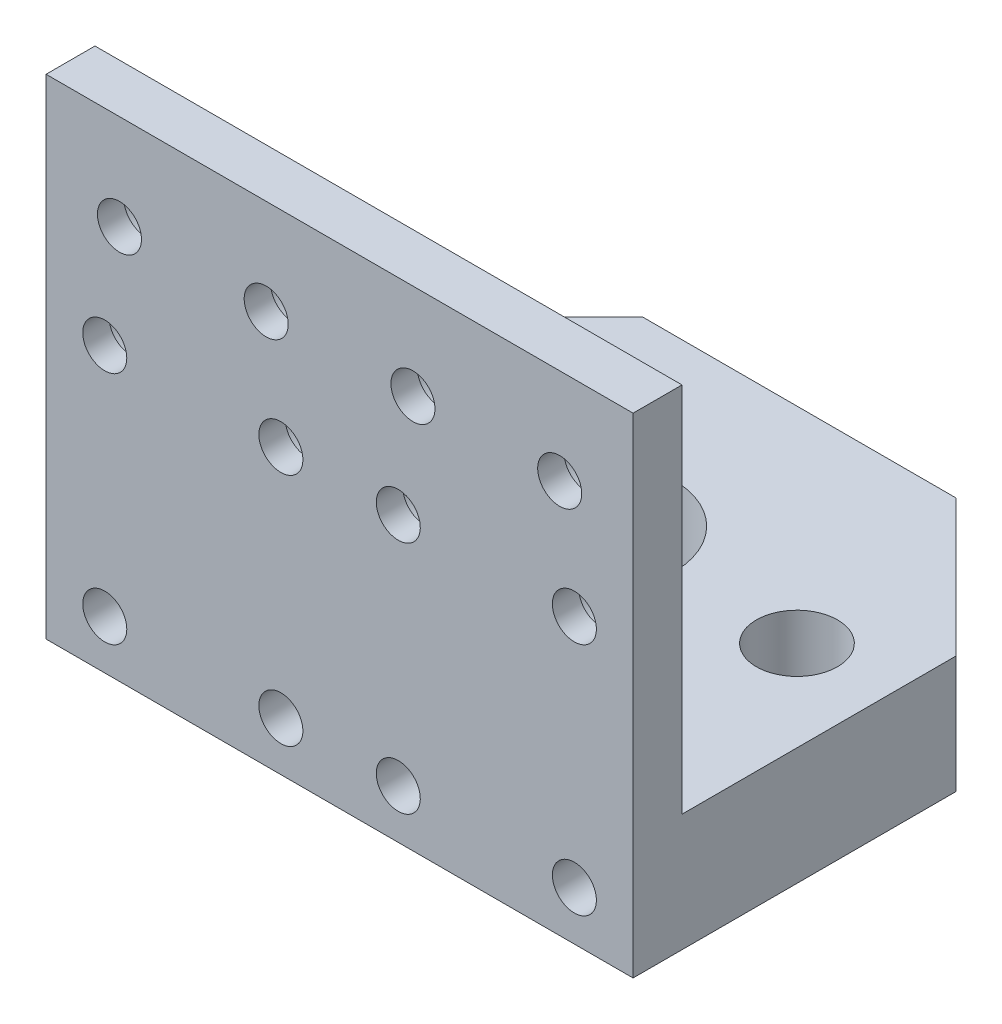
from build123d import *

# Parameters (mm, degrees)
SKETCH2_W                = 5
SKETCH2_H                = 50
BOSS_EXTRUDE1_DEPTH      = 30
BOSS_EXTRUDE1_DEPTH_BACK = 30
SKETCH3_W                = 60
SKETCH3_H                = 12
BOSS_EXTRUDE2_DEPTH      = 42
CUT_EXTRUDE1_REACH       = 49
SKETCH4_R                = 2.25
SKETCH6_R                = 4
CUT_EXTRUDE2_DEPTH       = 2.3
SKETCH7_R                = 2.25
CUT_EXTRUDE3_DEPTH       = 5
SKETCH8_R                = 4
CUT_EXTRUDE4_DEPTH       = 2.3
SKETCH9_R                = 8.15
SKETCH9_R_2              = 4.15
CUT_EXTRUDE5_DEPTH       = 10
CUT_EXTRUDE6_REACH       = 4
SKETCH10_R               = 7.5
SKETCH10_R_2             = 3
CHAMFER1_SIZE            = 14


with BuildPart() as part:
    # Sketch2 → Boss-Extrude1 (new body, two sides)
    with BuildSketch(Plane(origin=(0, 0, 0), x_dir=(0, 0, -1), z_dir=(1, 0, 0))) as boss_extrude1_sk:
        with Locations((13, -32)):
            Rectangle(SKETCH2_W, SKETCH2_H)
    extrude(amount=BOSS_EXTRUDE1_DEPTH)
    extrude(boss_extrude1_sk.sketch, amount=-BOSS_EXTRUDE1_DEPTH_BACK)

    # Sketch3 → Boss-Extrude2 (add)
    with BuildSketch(Plane(origin=(0, 0, -15.5), x_dir=(-1, 0, 0), z_dir=(0, 0, -1))):
        with Locations((0, -51)):
            Rectangle(SKETCH3_W, SKETCH3_H)
    extrude(amount=BOSS_EXTRUDE2_DEPTH)

    # Sketch4 → Cut-Extrude1 (cut, up to next)
    with BuildSketch(Plane.XY.offset(-10.5), mode=Mode.PRIVATE) as cut_extrude1_sk1:
        with Locations((-22.5, -16.75)):
            Circle(SKETCH4_R)
    cut_extrude1_tool1 = extrude(cut_extrude1_sk1.sketch, amount=-CUT_EXTRUDE1_REACH, mode=Mode.PRIVATE) & part.part
    add(cut_extrude1_tool1.solids().sort_by_distance((-22.5, -16.75, -10.5))[0], mode=Mode.SUBTRACT)
    # Sketch4 → Cut-Extrude1 (cut, up to next)
    with BuildSketch(Plane.XY.offset(-10.5), mode=Mode.PRIVATE) as cut_extrude1_sk2:
        with Locations((-7.5, -16.75)):
            Circle(SKETCH4_R)
    cut_extrude1_tool2 = extrude(cut_extrude1_sk2.sketch, amount=-CUT_EXTRUDE1_REACH, mode=Mode.PRIVATE) & part.part
    add(cut_extrude1_tool2.solids().sort_by_distance((-7.5, -16.75, -10.5))[0], mode=Mode.SUBTRACT)
    # Sketch4 → Cut-Extrude1 (cut, up to next)
    with BuildSketch(Plane.XY.offset(-10.5), mode=Mode.PRIVATE) as cut_extrude1_sk3:
        with Locations((7.5, -16.75)):
            Circle(SKETCH4_R)
    cut_extrude1_tool3 = extrude(cut_extrude1_sk3.sketch, amount=-CUT_EXTRUDE1_REACH, mode=Mode.PRIVATE) & part.part
    add(cut_extrude1_tool3.solids().sort_by_distance((7.5, -16.75, -10.5))[0], mode=Mode.SUBTRACT)
    # Sketch4 → Cut-Extrude1 (cut, up to next)
    with BuildSketch(Plane.XY.offset(-10.5), mode=Mode.PRIVATE) as cut_extrude1_sk4:
        with Locations((22.5, -16.75)):
            Circle(SKETCH4_R)
    cut_extrude1_tool4 = extrude(cut_extrude1_sk4.sketch, amount=-CUT_EXTRUDE1_REACH, mode=Mode.PRIVATE) & part.part
    add(cut_extrude1_tool4.solids().sort_by_distance((22.5, -16.75, -10.5))[0], mode=Mode.SUBTRACT)

    # Sketch6 → Cut-Extrude2 (cut)
    with BuildSketch(Plane(origin=(0, 0, -15.5), x_dir=(-1, 0, 0), z_dir=(0, 0, -1))):
        with Locations((-22.5, -16.75)):
            Circle(SKETCH6_R)
        with Locations((-7.5, -16.75)):
            Circle(SKETCH6_R)
        with Locations((7.5, -16.75)):
            Circle(SKETCH6_R)
        with Locations((22.5, -16.75)):
            Circle(SKETCH6_R)
    extrude(amount=-CUT_EXTRUDE2_DEPTH, mode=Mode.SUBTRACT)

    # Sketch7 → Cut-Extrude3 (cut)
    with BuildSketch(Plane.XY.offset(-10.5)):
        with Locations((-24, -52)):
            Circle(SKETCH7_R)
        with Locations((-6, -52)):
            Circle(SKETCH7_R)
        with Locations((-24, -28)):
            Circle(SKETCH7_R)
        with Locations((-6, -28)):
            Circle(SKETCH7_R)
        with Locations((6, -28)):
            Circle(SKETCH7_R)
        with Locations((24, -28)):
            Circle(SKETCH7_R)
        with Locations((6, -52)):
            Circle(SKETCH7_R)
        with Locations((24, -52)):
            Circle(SKETCH7_R)
    extrude(amount=-CUT_EXTRUDE3_DEPTH, mode=Mode.SUBTRACT)

    # Sketch8 → Cut-Extrude4 (cut)
    with BuildSketch(Plane(origin=(0, 0, -15.5), x_dir=(-1, 0, 0), z_dir=(0, 0, -1))):
        with Locations((-24, -28)):
            Circle(SKETCH8_R)
        with Locations((-6, -28)):
            Circle(SKETCH8_R)
        with Locations((6, -28)):
            Circle(SKETCH8_R)
        with Locations((24, -28)):
            Circle(SKETCH8_R)
    extrude(amount=-CUT_EXTRUDE4_DEPTH, mode=Mode.SUBTRACT)

    # Sketch9 → Cut-Extrude5 (cut)
    with BuildSketch(Plane(origin=(0, -45, 0), x_dir=(1, 0, 0), z_dir=(0, 1, 0))):
        with Locations((0, 36.5)):
            Circle(SKETCH9_R)
        with Locations((-20.75, 36.5)):
            Circle(SKETCH9_R_2)
        with Locations((20.75, 36.5)):
            Circle(SKETCH9_R_2)
    extrude(amount=-CUT_EXTRUDE5_DEPTH, mode=Mode.SUBTRACT)

    # Sketch10 → Cut-Extrude6 (cut, up to next)
    with BuildSketch(Plane(origin=(0, -55, 0), x_dir=(1, 0, 0), z_dir=(0, 1, 0)), mode=Mode.PRIVATE) as cut_extrude6_sk1:
        with Locations((0, 36.5)):
            Circle(SKETCH10_R)
    cut_extrude6_tool1 = extrude(cut_extrude6_sk1.sketch, amount=-CUT_EXTRUDE6_REACH, mode=Mode.PRIVATE) & part.part
    add(cut_extrude6_tool1.solids().sort_by_distance((0, -55, -36.5))[0], mode=Mode.SUBTRACT)
    # Sketch10 → Cut-Extrude6 (cut, up to next)
    with BuildSketch(Plane(origin=(0, -55, 0), x_dir=(1, 0, 0), z_dir=(0, 1, 0)), mode=Mode.PRIVATE) as cut_extrude6_sk2:
        with Locations((-20.75, 36.5)):
            Circle(SKETCH10_R_2)
    cut_extrude6_tool2 = extrude(cut_extrude6_sk2.sketch, amount=-CUT_EXTRUDE6_REACH, mode=Mode.PRIVATE) & part.part
    add(cut_extrude6_tool2.solids().sort_by_distance((-20.75, -55, -36.5))[0], mode=Mode.SUBTRACT)
    # Sketch10 → Cut-Extrude6 (cut, up to next)
    with BuildSketch(Plane(origin=(0, -55, 0), x_dir=(1, 0, 0), z_dir=(0, 1, 0)), mode=Mode.PRIVATE) as cut_extrude6_sk3:
        with Locations((20.75, 36.5)):
            Circle(SKETCH10_R_2)
    cut_extrude6_tool3 = extrude(cut_extrude6_sk3.sketch, amount=-CUT_EXTRUDE6_REACH, mode=Mode.PRIVATE) & part.part
    add(cut_extrude6_tool3.solids().sort_by_distance((20.75, -55, -36.5))[0], mode=Mode.SUBTRACT)

    # Chamfer1
    chamfer1_edges = [part.edges().sort_by_distance(p)[0] for p in [
        (30, -51, -57.5),
        (-30, -51, -57.5),
    ]]
    chamfer(chamfer1_edges, length=CHAMFER1_SIZE)


solid = part.part
